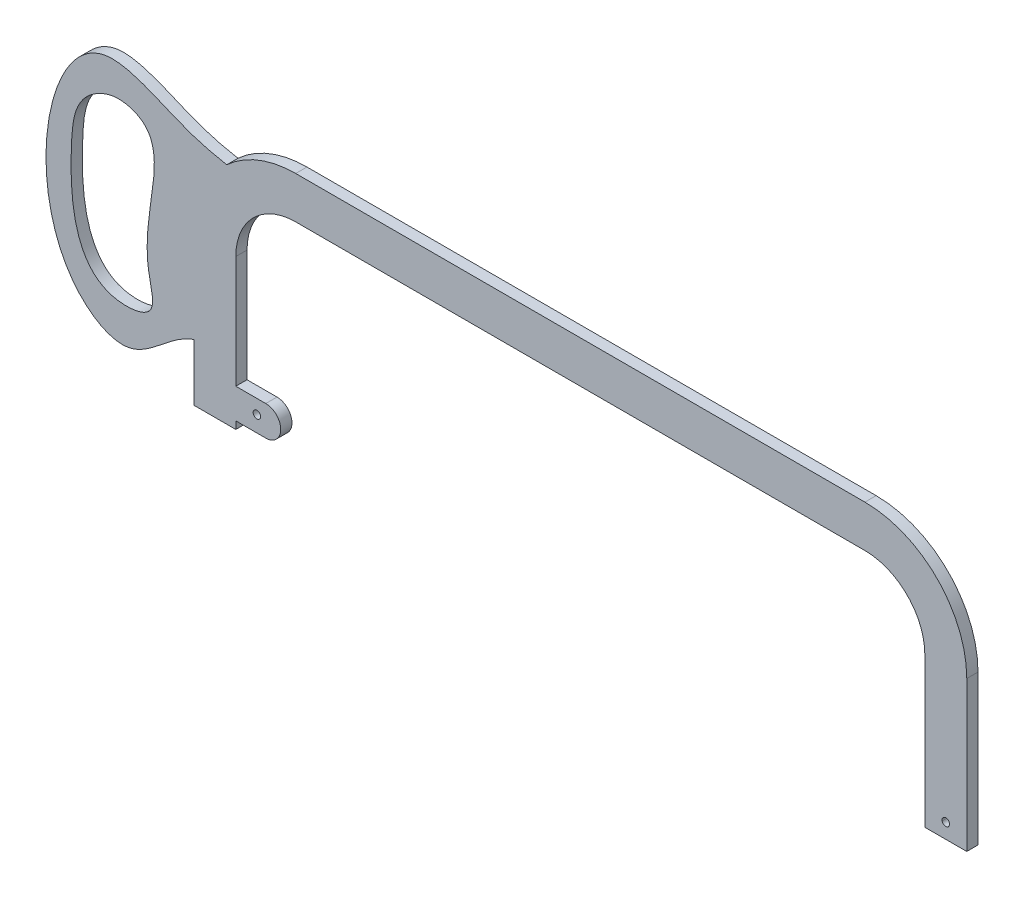
from build123d import *

# Parameters (mm, degrees)
EXTRUDE1_DEPTH     = 2.38125
EXTRUDE2_DEPTH     = 4.7625
SKETCH5_R          = 1.5875
CUT_EXTRUDE1_DEPTH = 5.7625
EXTRUDE3_DEPTH     = 4.7625


with BuildPart() as part:
    # Sketch2 → Extrude1 (new body, symmetric)
    with BuildSketch(Plane.XY):
        with BuildLine():
            Line((-176.25281746, 0), (-176.25281746, 63.5))
            ThreePointArc((-176.25281746, 63.5), (-168.813329702, 81.460512242), (-150.85281746, 88.9))
            Line((-150.85281746, 88.9), (90.44718254, 88.9))
            ThreePointArc((90.44718254, 88.9), (108.407694782, 81.460512242), (115.84718254, 63.5))
            Line((115.84718254, 63.5), (115.84718254, 0))
            Line((115.84718254, 0), (133.62718254, 0))
            Line((133.62718254, 0), (133.62718254, 63.5))
            ThreePointArc((133.62718254, 63.5), (120.980053351, 94.032870812), (90.44718254, 106.68))
            Line((90.44718254, 106.68), (-150.85281746, 106.68))
            ThreePointArc((-150.85281746, 106.68), (-181.385688272, 94.032870812), (-194.03281746, 63.5))
            Line((-194.03281746, 63.5), (-194.03281746, 0))
            Line((-194.03281746, 0), (-176.25281746, 0))
        make_face()
    extrude(amount=EXTRUDE1_DEPTH, both=True)

    # Sketch4 → Extrude2 (add)
    with BuildSketch(Plane.XY.offset(2.38125)):
        with BuildLine():
            Line((-176.25281746, 3.175), (-163.55281746, 3.175))
            ThreePointArc((-163.55281746, 3.175), (-157.20281746, 9.525), (-163.55281746, 15.875))
            Line((-163.55281746, 15.875), (-176.25281746, 15.875))
            Line((-176.25281746, 15.875), (-176.25281746, 3.175))
        make_face()
    extrude(amount=-EXTRUDE2_DEPTH)

    # Sketch5 → Cut-Extrude1 (cut, through all)
    with BuildSketch(Plane.XY.offset(2.38125)):
        with Locations((-167.33627827, 9.938552165)):
            Circle(SKETCH5_R)
        with Locations((124.73718254, 6.35)):
            Circle(SKETCH5_R)
    extrude(amount=-CUT_EXTRUDE1_DEPTH, mode=Mode.SUBTRACT)

    # Sketch6 → Extrude3 (add)
    with BuildSketch(Plane.XY.offset(2.38125)):
        with BuildLine():
            ThreePointArc((-194.03281746, 63.5), (-190.395106812, 80.847038733), (-180.094894681, 95.271265632))
            add(Edge.make_bspline(
                [(-180.094894681, 95.271265632), (-185.341131031, 96.218218934), (-202.678586654, 100.368767038), (-252.859222164, 130.124714634), (-269.426470803, 29.793267068), (-218.564814759, -0.415300215), (-204.063319668, 20.984062879), (-194.03281746, 24.12050612)],
                knots=[0.074848453, 0.074848453, 0.074848453, 0.074848453, 0.145421677, 0.306167094, 0.711218283, 0.818840041, 0.961035302, 0.961035302, 0.961035302, 0.961035302], degree=3))
            Line((-194.03281746, 24.12050612), (-194.03281746, 63.5))
        make_face()
        with BuildLine():
            add(Edge.make_bspline(
                [(-241.01195368, 88.809462375), (-244.988611476, 83.648741024), (-247.283551882, 60.105540958), (-244.91572239, 18.853735284), (-208.081682808, 23.123723469), (-220.297957577, 55.393154739), (-201.095560901, 90.740536107), (-229.023756485, 98.126858588), (-237.642234652, 93.182526848), (-241.01195368, 88.809462375)],
                knots=[0, 0, 0, 0, 0.110817881, 0.392381603, 0.473965197, 0.559095553, 0.859488044, 0.906095736, 1, 1, 1, 1], degree=3))
        make_face(mode=Mode.SUBTRACT)
    extrude(amount=-EXTRUDE3_DEPTH)


solid = part.part
